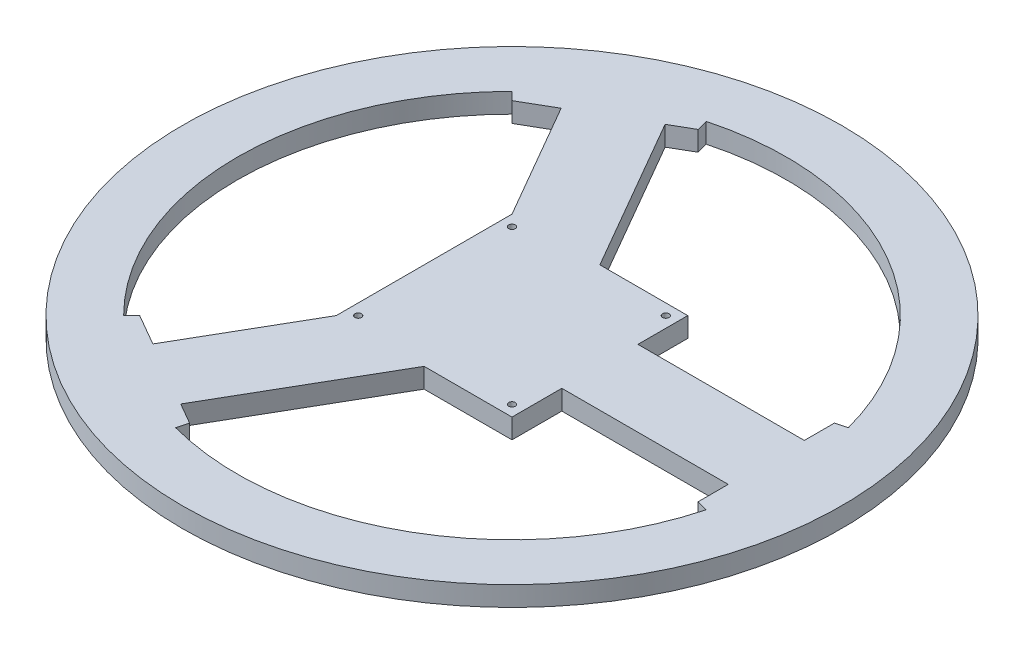
from build123d import *

# Parameters (mm, degrees)
CROQUIS1_R              = 150
CROQUIS1_R_2            = 125
SALIENTE_EXTRUIR1_DEPTH = 9
SALIENTE_EXTRUIR3_DEPTH = 9
CROQUIS3_R              = 1.5
SALIENTE_EXTRUIR4_DEPTH = 9


with BuildPart() as part:
    # Croquis1 → Saliente-Extruir1 (new body)
    with BuildSketch(Plane(origin=(0, 0, 0), x_dir=(1, 0, 0), z_dir=(0, 1, 0))):
        Circle(CROQUIS1_R)
        Circle(CROQUIS1_R_2, mode=Mode.SUBTRACT)
    extrude(amount=SALIENTE_EXTRUIR1_DEPTH)

    # Croquis2 → Saliente-Extruir3 (add)
    with BuildSketch(Plane(origin=(0, 0, 0), x_dir=(1, 0, 0), z_dir=(0, 1, 0))):
        Polygon((120.740728286, 32.352380638), (146.469530849, 32.352380638), (146.469530849, -32.352380638), (120.740728286, -32.352380638), (115.740728286, -31.012634676), (115.740728286, 31.012634676), align=None)
        Polygon((-88.388347648, -88.388347648), (-101.25274893, -110.670144277), (-45.216781919, -143.022524914), (-32.352380638, -120.740728286), (-31.012634676, -115.740728286), (-84.72809361, -84.72809361), align=None)
        Polygon((-32.352380638, 120.740728286), (-45.216781919, 143.022524914), (-101.25274893, 110.670144277), (-88.388347648, 88.388347648), (-84.72809361, 84.72809361), (-31.012634676, 115.740728286), align=None)
    extrude(amount=SALIENTE_EXTRUIR3_DEPTH)

    # Croquis3 → Saliente-Extruir4 (add)
    with BuildSketch(Plane(origin=(0, 0, 0), x_dir=(1, 0, 0), z_dir=(0, 1, 0))):
        Polygon((-70.549856067, 92.913902873), (-40, 40), (-40, -40), (-70.549856067, -92.913902873), (-40.549856067, -110.234410948), (0, -40), (40, -40), (40, -17.32), (115.740728286, -17.32), (115.740728286, 17.32), (40, 17.32), (40, 40), (0, 40), (-40.549856067, 110.234410948), align=None)
        with Locations((-35, 35)):
            Circle(CROQUIS3_R, mode=Mode.SUBTRACT)
        with Locations((35, 35)):
            Circle(CROQUIS3_R, mode=Mode.SUBTRACT)
        with Locations((35, -35)):
            Circle(CROQUIS3_R, mode=Mode.SUBTRACT)
        with Locations((-35, -35)):
            Circle(CROQUIS3_R, mode=Mode.SUBTRACT)
    extrude(amount=SALIENTE_EXTRUIR4_DEPTH)


solid = part.part
